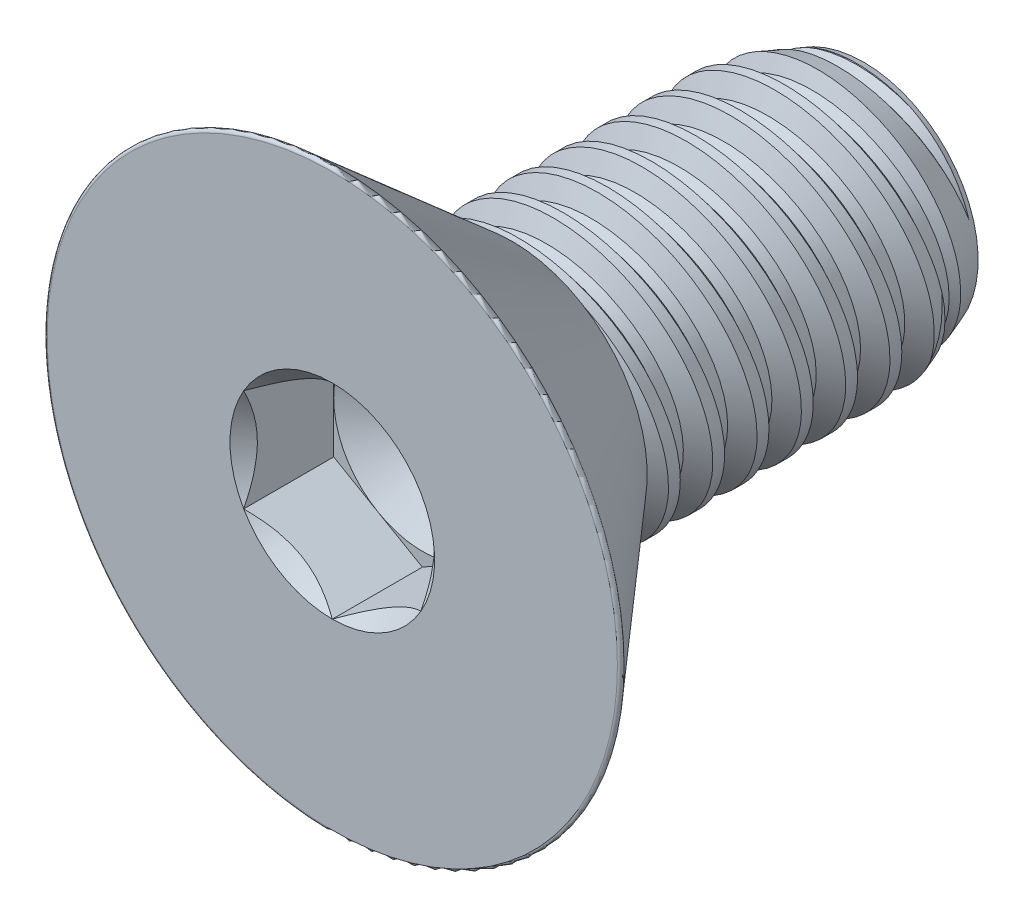
from build123d import *

# Parameters (mm, degrees)
SKETCH1_W          = 6.2992
SKETCH1_H          = 2.413
LPATTERN1_COUNT    = 8
LPATTERN1_PITCH    = 0.79375
LPATTERN2_COUNT    = 2
LPATTERN2_PITCH    = 0.79375
SKETCH4_R          = 5.2197
EXTRUDE1_DEPTH     = 3.2258
FILLET1_R          = 0.0508
CUT_EXTRUDE1_DEPTH = 1.6129
SKETCH7_R          = 1.833087105
CUT_EXTRUDE4_DEPTH = 1.6129
CUT_EXTRUDE4_TAPER = 45
SKETCH8_R          = 1.5875
CUT_EXTRUDE5_DEPTH = 0.537633333
CUT_EXTRUDE5_TAPER = 60


with BuildPart() as part:
    # Sketch1 → Revolve1 (revolve)
    with BuildSketch(Plane(origin=(0, 0, 0), x_dir=(0, 0, -1), z_dir=(1, 0, 0))):
        with Locations((3.1496, 1.2065)):
            Rectangle(SKETCH1_W, SKETCH1_H)
    revolve(axis=Axis((0, 0, 0), (0, 0, 1)))

    # Sketch2 → Cut-Revolve1 (revolve, cut)
    with BuildSketch(Plane(origin=(0, 0, 0), x_dir=(0, 0, -1), z_dir=(1, 0, 0))):
        Polygon((0.097903365, 2.429102527), (0.783226924, 2.541820218), (0.608194498, 2.077629892), (0.412387767, 2.045424837), align=None)
    cut_revolve1 = revolve(axis=Axis((0, -0.139697061, 0), (0, 0.162293188, -0.986742581)), mode=Mode.SUBTRACT)

    # Sketch3 → Cut-Revolve2 (revolve, cut)
    with BuildSketch(Plane(origin=(0, 0, 0), x_dir=(0, 0, -1), z_dir=(1, 0, 0))):
        Polygon((6.2992, 2.045424837), (5.28929554, 2.413), (6.2992, 2.413), align=None)
    revolve(axis=Axis((0, 0, -5.28929554), (0, 0, 1)), mode=Mode.SUBTRACT)

    # LPattern1: Cut-Revolve1 ×8
    with Locations(*[(0, 0, -i * LPATTERN1_PITCH) for i in range(1, LPATTERN1_COUNT)]):
        add(cut_revolve1, mode=Mode.SUBTRACT)

    # LPattern2: Cut-Revolve1 ×2
    with Locations(*[(0, 0, i * LPATTERN2_PITCH) for i in range(1, LPATTERN2_COUNT)]):
        add(cut_revolve1, mode=Mode.SUBTRACT)

    # Sketch4 → Extrude1 (add)
    with BuildSketch(Plane.XY):
        Circle(SKETCH4_R)
    extrude(amount=EXTRUDE1_DEPTH)

    # Sketch9 → Cut-Revolve3 (revolve, cut)
    with BuildSketch(Plane(origin=(0, 0, 0), x_dir=(0, 0, -1), z_dir=(1, 0, 0))):
        Polygon((-3.2258, 5.2197), (0, 2.415554841), (0, 5.2197), align=None)
    revolve(axis=Axis((0, 0, 0), (0, 0, 1)), mode=Mode.SUBTRACT)

    # Fillet1
    fillet1_edges = [part.edges().sort_by_distance(p)[0] for p in [
        (0, -5.2197, 3.2258),
    ]]
    fillet(fillet1_edges, radius=FILLET1_R)

    # Sketch6 → Cut-Extrude1 (cut)
    with BuildSketch(Plane.XY.offset(3.2258)):
        Polygon((0, -1.833087105), (1.5875, -0.916543552), (1.5875, 0.916543552), (0, 1.833087105), (-1.5875, 0.916543552), (-1.5875, -0.916543552), align=None)
    extrude(amount=-CUT_EXTRUDE1_DEPTH, mode=Mode.SUBTRACT)

    # Sketch7 → Cut-Extrude4 (cut)
    with BuildSketch(Plane.XY.offset(3.2258)):
        Circle(SKETCH7_R)
    extrude(amount=-CUT_EXTRUDE4_DEPTH, taper=CUT_EXTRUDE4_TAPER, mode=Mode.SUBTRACT)

    # Sketch8 → Cut-Extrude5 (cut)
    with BuildSketch(Plane.XY.offset(1.6129)):
        Circle(SKETCH8_R)
    extrude(amount=-CUT_EXTRUDE5_DEPTH, taper=CUT_EXTRUDE5_TAPER, mode=Mode.SUBTRACT)


solid = part.part
